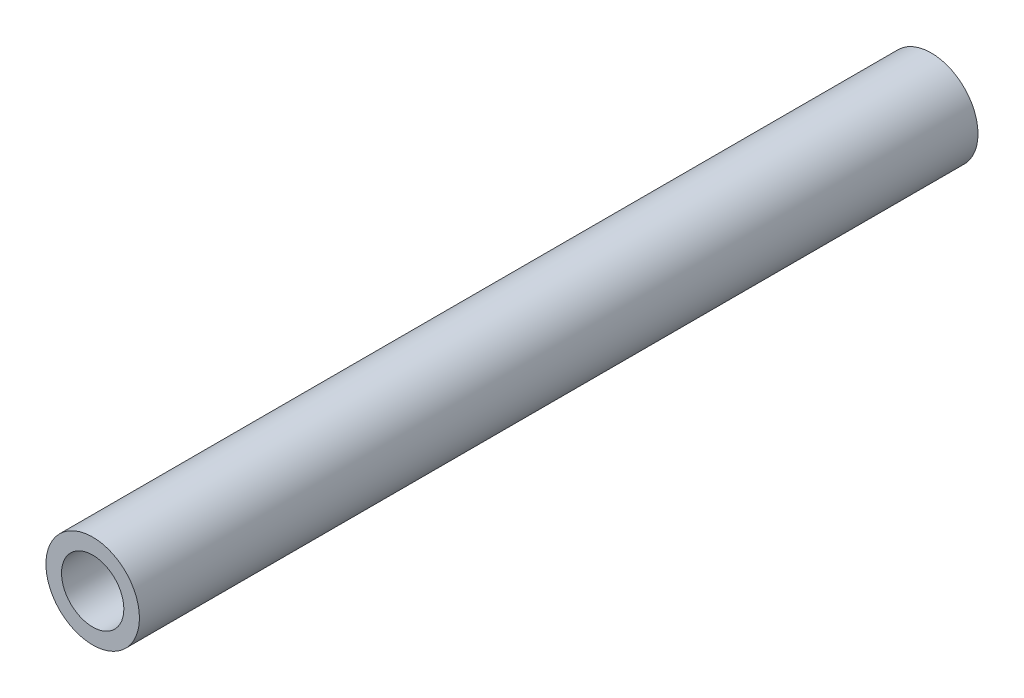
from build123d import *

# Parameters (mm, degrees)
SKETCH1_R           = 7.62
SKETCH1_R_2         = 5.08
BOSS_EXTRUDE1_DEPTH = 136.652


with BuildPart() as part:
    # Sketch1 → Boss-Extrude1 (new body)
    with BuildSketch(Plane.XY):
        Circle(SKETCH1_R)
        Circle(SKETCH1_R_2, mode=Mode.SUBTRACT)
    extrude(amount=BOSS_EXTRUDE1_DEPTH)


solid = part.part
